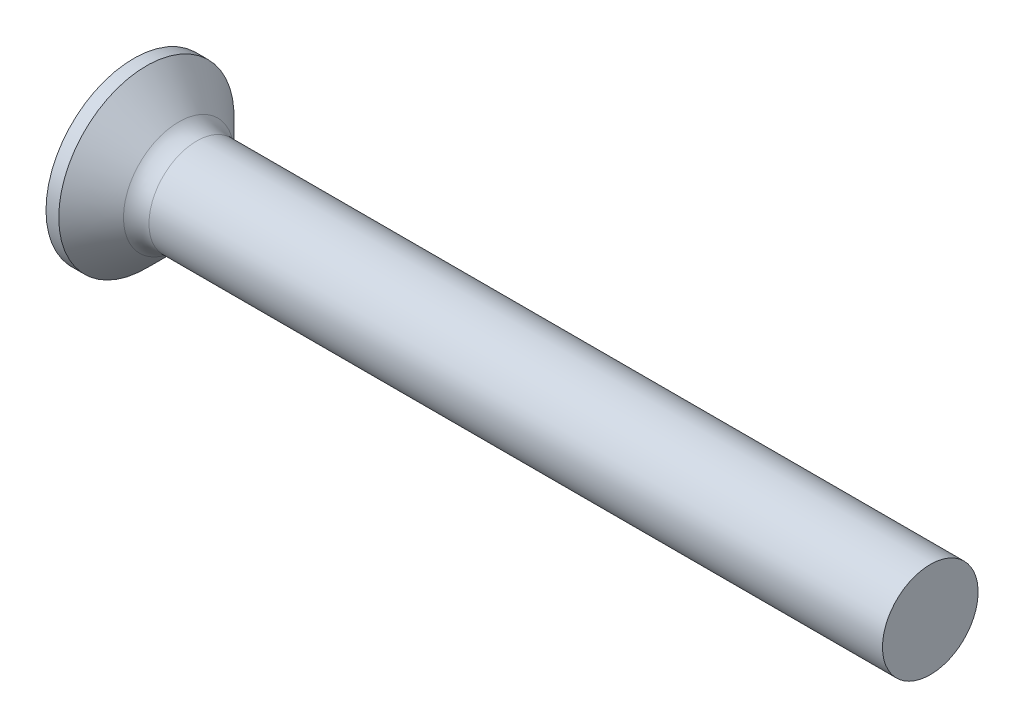
from build123d import *

# Parameters (mm, degrees)
FILLET1_R    = 0.8
SKETCH3_W    = 0.74
SKETCH3_H    = 3
SKETCH4_W    = 0.74
SKETCH4_H    = 0.995702004
RECPAT_COUNT = 2
RECPAT_ANGLE = 90


with BuildPart() as part:
    # BodySke → Base-Revolve (revolve)
    with BuildSketch(Plane.XY):
        Polygon((0, 0), (0, 2.75), (0.4, 2.75), (1.65, 1.5), (25, 1.5), (25, 0), align=None)
    revolve(axis=Axis((-6.35, 0, 0), (1, 0, 0)))

    # Fillet1
    fillet1_edges = [part.edges().sort_by_distance(p)[0] for p in [
        (1.65, -1.5, 0),
    ]]
    fillet(fillet1_edges, radius=FILLET1_R)

    # Sketch3 → Recess section 0
    with BuildSketch(Plane.ZY):
        Rectangle(SKETCH3_W, SKETCH3_H)
    # Sketch4 → Recess section 1
    with BuildSketch(Plane.ZY.offset(-2.01)):
        Rectangle(SKETCH4_W, SKETCH4_H)
    recess = loft(mode=Mode.SUBTRACT)

    # RecPat: Recess ×2 about axis
    recpat_axis = Axis((0, 0, 0), (1, 0, 0))
    for i in range(1, RECPAT_COUNT):
        add(recess.rotate(recpat_axis, i * RECPAT_ANGLE / (RECPAT_COUNT - 1)), mode=Mode.SUBTRACT)

    # RecCorSke → RecessCore (revolve, cut)
    with BuildSketch(Plane.XY):
        Polygon((0, 0), (0, 0.696552892), (2.01, 0.556), (2.190655351, 0), align=None)
    revolve(axis=Axis((-3.175, 0, 0), (1, 0, 0)), mode=Mode.SUBTRACT)


solid = part.part
